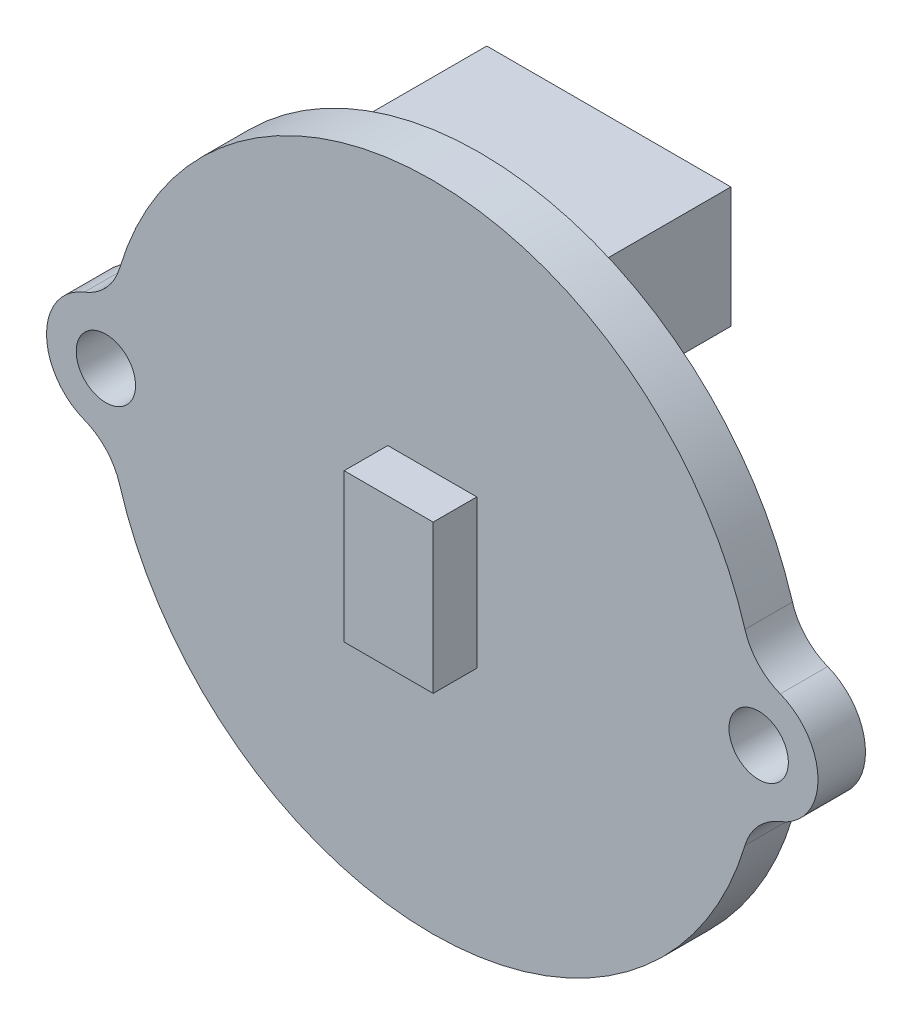
from build123d import *

# Parameters (mm, degrees)
SKETCH_1_R      = 1
EXTRUDE_1_DEPTH = 1.6
SKETCH_2_W      = 3
SKETCH_2_H      = 5
EXTRUDE_2_DEPTH = 1.47
SKETCH_3_W      = 8.226
SKETCH_3_H      = 4.069
EXTRUDE_3_DEPTH = 4.35


with BuildPart() as part:
    # 草图1 → 凸台-拉伸1 (new body)
    with BuildSketch(Plane.XY):
        with BuildLine():
            ThreePointArc((-10.538461538, -3.152907928), (0, -11), (10.538461538, -3.152907928))
            ThreePointArc((10.538461538, -3.152907928), (10.98391758, -2.370710612), (11.727272727, -1.863081957))
            ThreePointArc((11.727272727, -1.863081957), (13, 0), (11.727272727, 1.863081957))
            ThreePointArc((11.727272727, 1.863081957), (10.98391758, 2.370710612), (10.538461538, 3.152907928))
            ThreePointArc((10.538461538, 3.152907928), (0, 11), (-10.538461538, 3.152907928))
            ThreePointArc((-10.538461538, 3.152907928), (-10.98391758, 2.370710612), (-11.727272727, 1.863081957))
            ThreePointArc((-11.727272727, 1.863081957), (-13, 0), (-11.727272727, -1.863081957))
            ThreePointArc((-11.727272727, -1.863081957), (-10.98391758, -2.370710612), (-10.538461538, -3.152907928))
        make_face()
        with Locations((-11, 0)):
            Circle(SKETCH_1_R, mode=Mode.SUBTRACT)
        with Locations((11, 0)):
            Circle(SKETCH_1_R, mode=Mode.SUBTRACT)
    extrude(amount=EXTRUDE_1_DEPTH)

    # 草图2 → 凸台-拉伸2 (add)
    with BuildSketch(Plane.XY.offset(1.6)):
        Rectangle(SKETCH_2_W, SKETCH_2_H)
    extrude(amount=EXTRUDE_2_DEPTH)

    # 草图3 → 凸台-拉伸3 (add)
    with BuildSketch(Plane(origin=(0, 0, 0), x_dir=(-1, 0, 0), z_dir=(0, 0, -1))):
        with Locations((0, 7.8445)):
            Rectangle(SKETCH_3_W, SKETCH_3_H)
    extrude(amount=EXTRUDE_3_DEPTH)


solid = part.part
